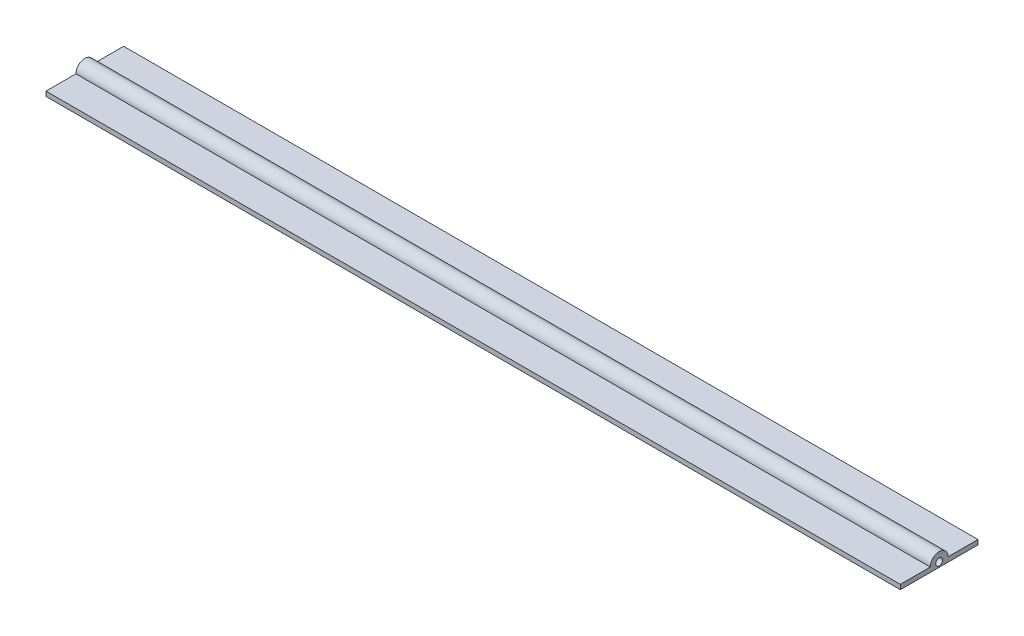
from build123d import *

# Parameters (mm, degrees)
BOSS_EXTRUDE1_DEPTH = 279.4
CUT_EXTRUDE1_REACH  = 281.4
SKETCH2_R           = 1.125613493


with BuildPart() as part:
    # Sketch1 → Boss-Extrude1 (new body)
    with BuildSketch(Plane(origin=(0, 0, 0), x_dir=(0, 0, -1), z_dir=(1, 0, 0))):
        with BuildLine():
            Line((15.612422091, 1.524), (25.4, 1.524))
            Line((25.4, 1.524), (25.4, 0))
            Line((25.4, 0), (0, 0))
            Line((0, 0), (0, 1.524))
            Line((0, 1.524), (9.787577909, 1.524))
            ThreePointArc((9.787577909, 1.524), (12.7, 4.436422091), (15.612422091, 1.524))
        make_face()
    extrude(amount=BOSS_EXTRUDE1_DEPTH)

    # Sketch2 → Cut-Extrude1 (cut, up to next)
    with BuildSketch(Plane(origin=(279.4, 0, 0), x_dir=(0, 0, -1), z_dir=(1, 0, 0)), mode=Mode.PRIVATE) as cut_extrude1_sk1:
        with Locations((12.7, 1.524)):
            Circle(SKETCH2_R)
    cut_extrude1_tool1 = extrude(cut_extrude1_sk1.sketch, amount=-CUT_EXTRUDE1_REACH, mode=Mode.PRIVATE) & part.part
    add(cut_extrude1_tool1.solids().sort_by_distance((279.4, 1.524, -12.7))[0], mode=Mode.SUBTRACT)


solid = part.part
